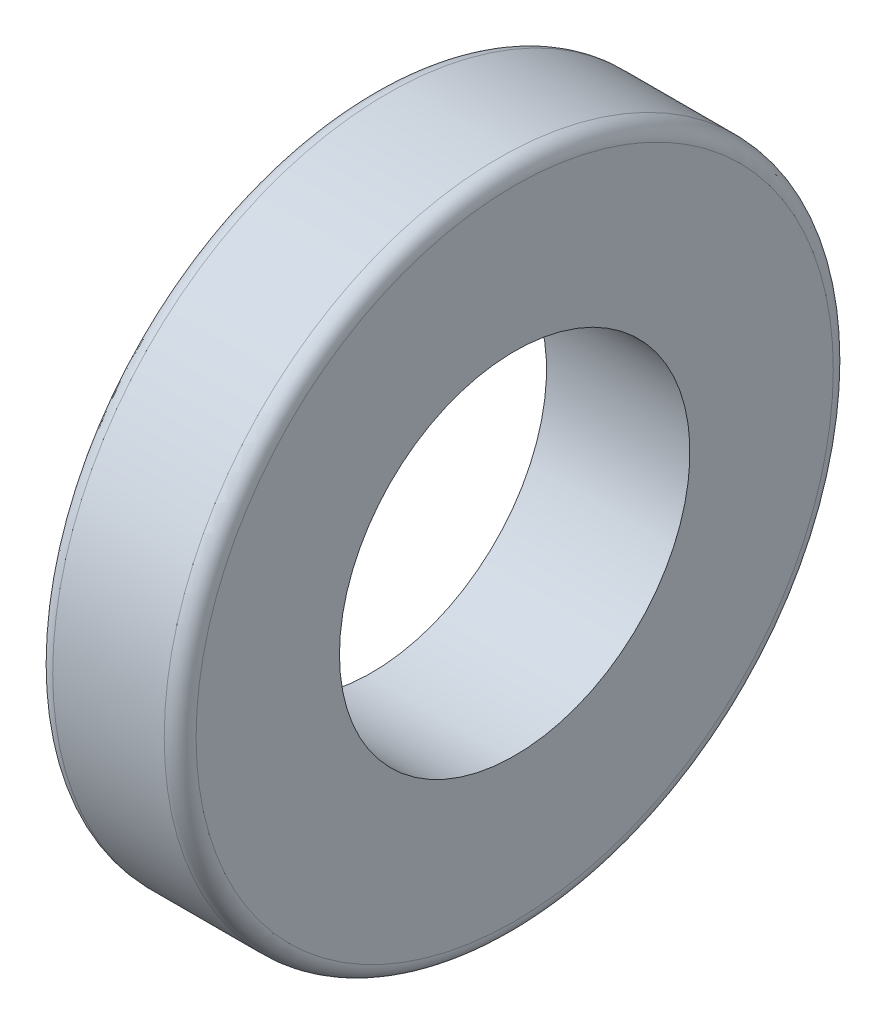
from build123d import *

# Parameters (mm, degrees)
SKETCH1_W = 4.5
SKETCH1_H = 5
FILLET1_R = 0.5


with BuildPart() as part:
    # Sketch1 → Revolve1 (revolve)
    with BuildSketch(Plane.XY):
        with Locations((3, 8)):
            Rectangle(SKETCH1_W, SKETCH1_H)
    revolve(axis=Axis((0, 0, 0), (1, 0, 0)))

    # Fillet1
    fillet1_edges = [part.edges().sort_by_distance(p)[0] for p in [
        (5.25, -10.5, 0),
        (0.75, -10.5, 0),
    ]]
    fillet(fillet1_edges, radius=FILLET1_R)


solid = part.part
